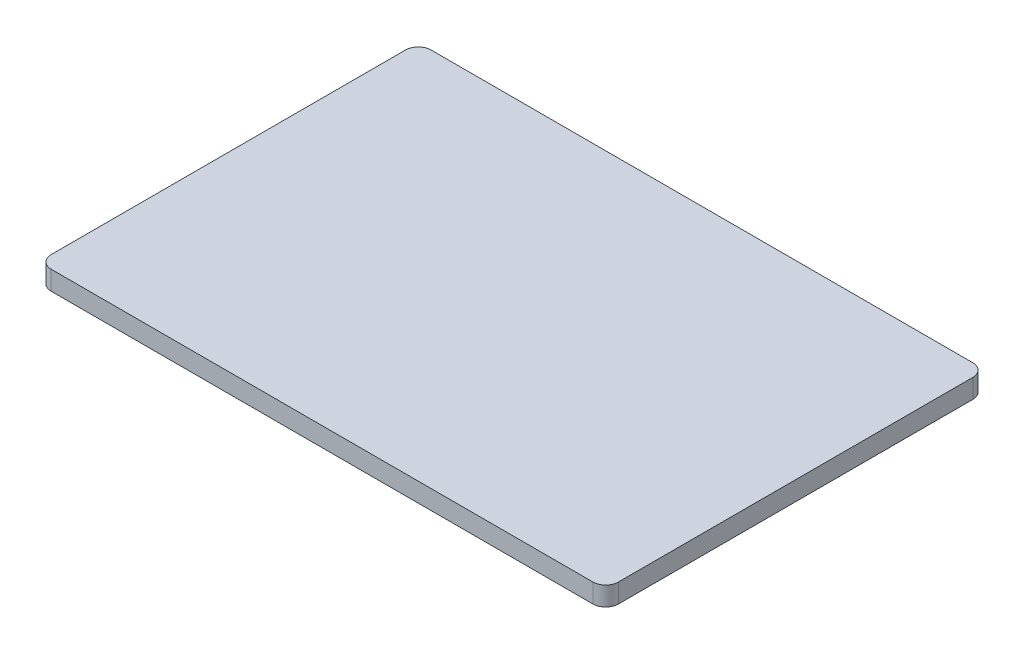
from build123d import *

# Parameters (mm, degrees)
SKETCH1_W           = 89.0392
SKETCH1_H           = 59.626
BOSS_EXTRUDE1_DEPTH = 2.9972
FILLET1_R           = 2


with BuildPart() as part:
    # Sketch1 → Boss-Extrude1 (new body)
    with BuildSketch(Plane(origin=(0, 0, 0), x_dir=(1, 0, 0), z_dir=(0, 1, 0))):
        Rectangle(SKETCH1_W, SKETCH1_H)
    extrude(amount=BOSS_EXTRUDE1_DEPTH)

    # Fillet1
    fillet1_edges = [part.edges().sort_by_distance(p)[0] for p in [
        (44.5196, 1.4986, 29.813),
        (-44.5196, 1.4986, 29.813),
        (-44.5196, 1.4986, -29.813),
        (44.5196, 1.4986, -29.813),
    ]]
    fillet(fillet1_edges, radius=FILLET1_R)


solid = part.part
